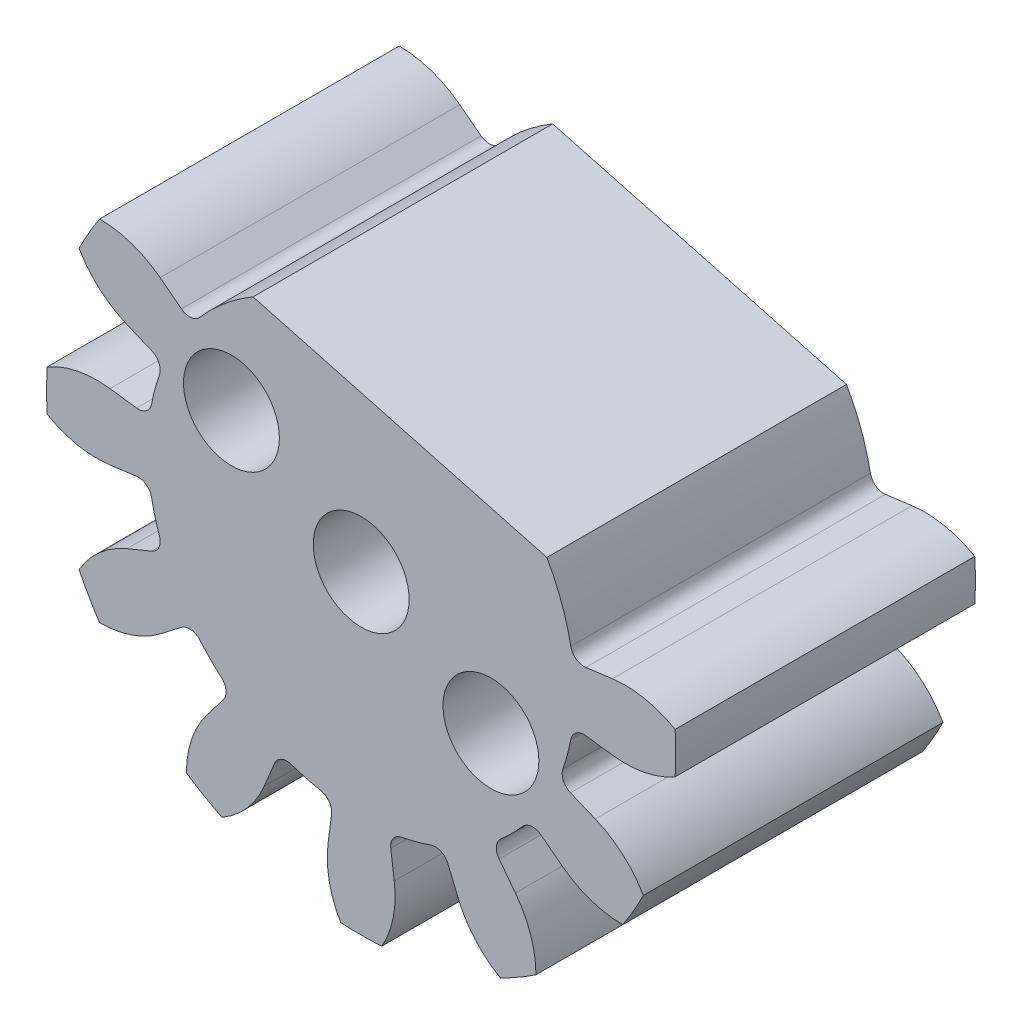
from build123d import *

# Parameters (mm, degrees)
BOSS_EXTRU_2_DEPTH                 = 10
CONG_1_R                           = 0.45
R_P_TITION_CIRCULAIRE1_COUNT       = 8
R_P_TITION_CIRCULAIRE1_ANGLE       = 210
CONG_1_OF_R_P_TITION_CIRCULAIRE1_R = 0.45
ESQUISSE5_R                        = 7.125
BOSS_EXTRU_4_DEPTH                 = 10
ENL_V_MAT_EXTRU_3_DEPTH            = 11
ESQUISSE3_R                        = 1.6
ENL_V_MAT_EXTRU_4_DEPTH            = 11
ESQUISSE8_R                        = 1.6
ENL_V_MAT_EXTRU_5_DEPTH            = 11


with BuildPart() as part:
    # Esquisse1 → Boss.-Extru.2 (new body)
    with BuildSketch(Plane.XY):
        with BuildLine():
            Line((0, 0), (6.882221512, 1.844085696))
            ThreePointArc((6.882221512, 1.844085696), (6.988095123, 1.390018544), (7.064044637, 0.92999912))
            Line((7.064044637, 0.92999912), (8.384880781, 1.103890497))
            ThreePointArc((8.384880781, 1.103890497), (9.465680859, 1.068283463), (10.477518694, 0.686732857))
            ThreePointArc((10.477518694, 0.686732857), (10.5, 0), (10.477518694, -0.686732857))
            ThreePointArc((10.477518694, -0.686732857), (9.465680859, -1.068283463), (8.384880781, -1.103890497))
            Line((8.384880781, -1.103890497), (7.064044637, -0.92999912))
            ThreePointArc((7.064044637, -0.92999912), (6.988095123, -1.390018544), (6.882221512, -1.844085696))
            Line((6.882221512, -1.844085696), (0, 0))
        make_face()
    boss_extru_2 = extrude(amount=BOSS_EXTRU_2_DEPTH)

    # Congé1
    cong_1_edges = [part.edges().sort_by_distance(p)[0] for p in [
        (7.064044637, 0.92999912, 5),
        (7.064044637, -0.92999912, 5),
    ]]
    fillet(cong_1_edges, radius=CONG_1_R)

    # Répétition circulaire1: Boss.-Extru.2 ×8 about axis
    r_p_tition_circulaire1_axis = Axis((0, 0, 0), (0, 0, -1))
    for i in range(1, R_P_TITION_CIRCULAIRE1_COUNT):
        add(boss_extru_2.rotate(r_p_tition_circulaire1_axis, i * R_P_TITION_CIRCULAIRE1_ANGLE / (R_P_TITION_CIRCULAIRE1_COUNT - 1)))

    # Congé1 of Répétition circulaire1
    cong_1_of_r_p_tition_circulaire1_edges = [part.edges().sort_by_distance(p)[0] for p in [
        (6.582641669, -2.726619456, 5),
        (5.65264255, -4.337425182, 5),
        (4.337425182, -5.65264255, 5),
        (2.726619456, -6.582641669, 5),
        (0.92999912, -7.064044637, 5),
        (-0.92999912, -7.064044637, 5),
        (-2.726619456, -6.582641669, 5),
        (-4.337425182, -5.65264255, 5),
        (-5.65264255, -4.337425182, 5),
        (-6.582641669, -2.726619456, 5),
        (-7.064044637, -0.92999912, 5),
        (-7.064044637, 0.92999912, 5),
        (-6.582641669, 2.726619456, 5),
        (-5.65264255, 4.337425182, 5),
    ]]
    fillet(cong_1_of_r_p_tition_circulaire1_edges, radius=CONG_1_OF_R_P_TITION_CIRCULAIRE1_R)

    # Esquisse5 → Boss.-Extru.4 (add, through all)
    with BuildSketch(Plane.XY.offset(10)):
        Circle(ESQUISSE5_R)
    extrude(amount=-BOSS_EXTRU_4_DEPTH)

    # Esquisse7 → Enlèv. mat.-Extru.3 (cut, through all)
    with BuildSketch(Plane.XY.offset(10)):
        with BuildLine():
            Line((-3.608929902, 6.143390755), (6.197120353, 3.515867508))
            ThreePointArc((6.197120353, 3.515867508), (1.844085696, 6.882221512), (-3.608929902, 6.143390755))
        make_face()
    extrude(amount=-ENL_V_MAT_EXTRU_3_DEPTH, mode=Mode.SUBTRACT)

    # Esquisse3 → Enlèv. mat.-Extru.4 (cut, through all)
    with BuildSketch(Plane.XY.offset(10)):
        Circle(ESQUISSE3_R)
    extrude(amount=-ENL_V_MAT_EXTRU_4_DEPTH, mode=Mode.SUBTRACT)

    # Esquisse8 → Enlèv. mat.-Extru.5 (cut, through all)
    with BuildSketch(Plane.XY.offset(10)):
        with Locations((-4.330127019, 2.5)):
            Circle(ESQUISSE8_R)
        with Locations((4.330127019, -2.5)):
            Circle(ESQUISSE8_R)
    extrude(amount=-ENL_V_MAT_EXTRU_5_DEPTH, mode=Mode.SUBTRACT)


solid = part.part
